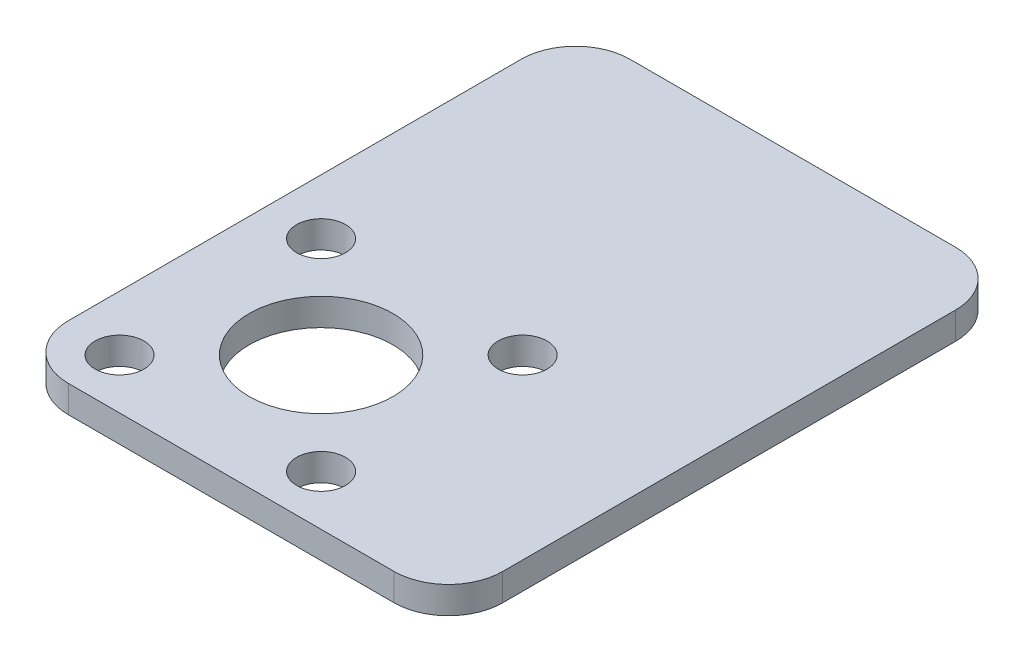
from build123d import *

# Parameters (mm, degrees)
CROQUIS1_W              = 32
CROQUIS1_H              = 41.37
CROQUIS1_R              = 5.3
SALIENTE_EXTRUIR1_DEPTH = 2
CROQUIS2_R              = 1.8
CORTAR_EXTRUIR1_DEPTH   = 2
MATRIZC1_COUNT          = 4
REDONDEO1_R             = 4


with BuildPart() as part:
    # Croquis1 → Saliente-Extruir1 (new body)
    with BuildSketch(Plane(origin=(0, 0, 0), x_dir=(1, 0, 0), z_dir=(0, 1, 0))):
        Rectangle(CROQUIS1_W, CROQUIS1_H)
        with Locations((-4.5, -9.565)):
            Circle(CROQUIS1_R, mode=Mode.SUBTRACT)
    extrude(amount=SALIENTE_EXTRUIR1_DEPTH)

    # Croquis2 → Cortar-Extruir1 (cut)
    with BuildSketch(Plane(origin=(0, 2, 0), x_dir=(1, 0, 0), z_dir=(0, 1, 0))):
        with Locations((2.924621202, -16.989621202)):
            Circle(CROQUIS2_R)
    cortar_extruir1 = extrude(amount=-CORTAR_EXTRUIR1_DEPTH, mode=Mode.SUBTRACT)

    # MatrizC1: Cortar-Extruir1 ×4 about axis
    matrizc1_axis = Axis((-4.5, 0, 9.565), (0, 1, 0))
    for i in range(1, MATRIZC1_COUNT):
        add(cortar_extruir1.rotate(matrizc1_axis, i * 360 / MATRIZC1_COUNT), mode=Mode.SUBTRACT)

    # Redondeo1
    redondeo1_edges = [part.edges().sort_by_distance(p)[0] for p in [
        (16, 1, 20.685),
        (-16, 1, 20.685),
        (-16, 1, -20.685),
        (16, 1, -20.685),
    ]]
    fillet(redondeo1_edges, radius=REDONDEO1_R)


solid = part.part
